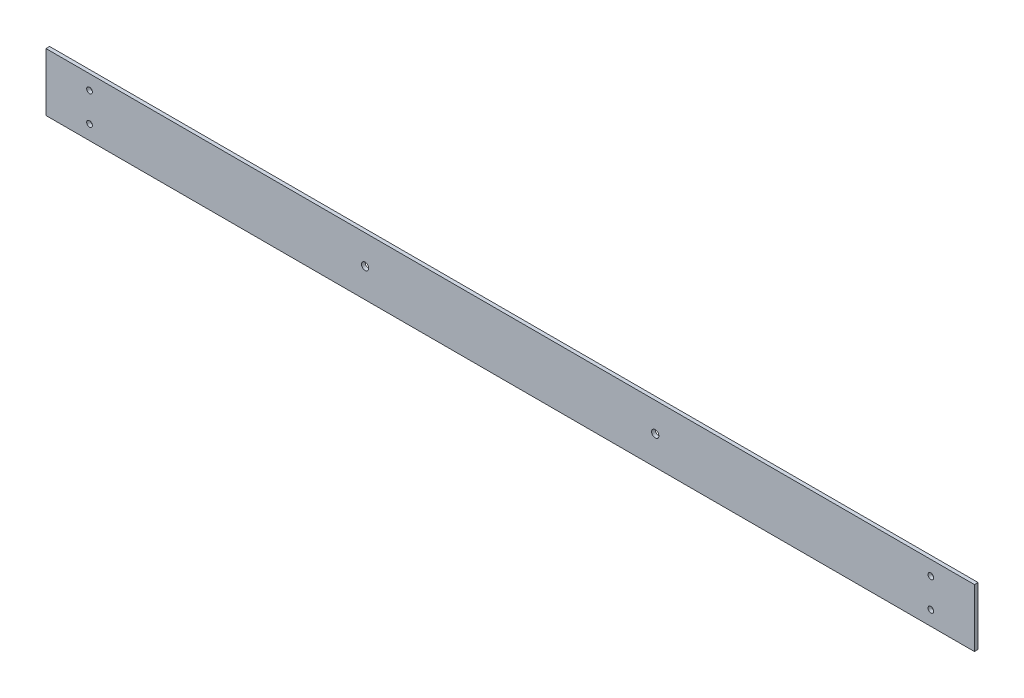
from build123d import *

# Parameters (mm, degrees)
SKETCH1_W           = 812.8
SKETCH1_H           = 50.8
BOSS_EXTRUDE1_DEPTH = 3.175
SKETCH2_R           = 3.175
SKETCH2_R_2         = 2.4892
CUT_EXTRUDE1_DEPTH  = 4.175


with BuildPart() as part:
    # Sketch1 → Boss-Extrude1 (new body)
    with BuildSketch(Plane.XY):
        with Locations((406.4, 25.4)):
            Rectangle(SKETCH1_W, SKETCH1_H)
    extrude(amount=BOSS_EXTRUDE1_DEPTH)

    # Sketch2 → Cut-Extrude1 (cut, through all)
    with BuildSketch(Plane(origin=(0, 0, 0), x_dir=(-1, 0, 0), z_dir=(0, 0, -1))):
        with Locations((-533.4, 25.4)):
            Circle(SKETCH2_R)
        with Locations((-279.4, 25.4)):
            Circle(SKETCH2_R)
        with Locations((-38.1, 12.7)):
            Circle(SKETCH2_R_2)
        with Locations((-38.1, 38.1)):
            Circle(SKETCH2_R_2)
        with Locations((-774.7, 12.7)):
            Circle(SKETCH2_R_2)
        with Locations((-774.7, 38.1)):
            Circle(SKETCH2_R_2)
    extrude(amount=-CUT_EXTRUDE1_DEPTH, mode=Mode.SUBTRACT)


solid = part.part
